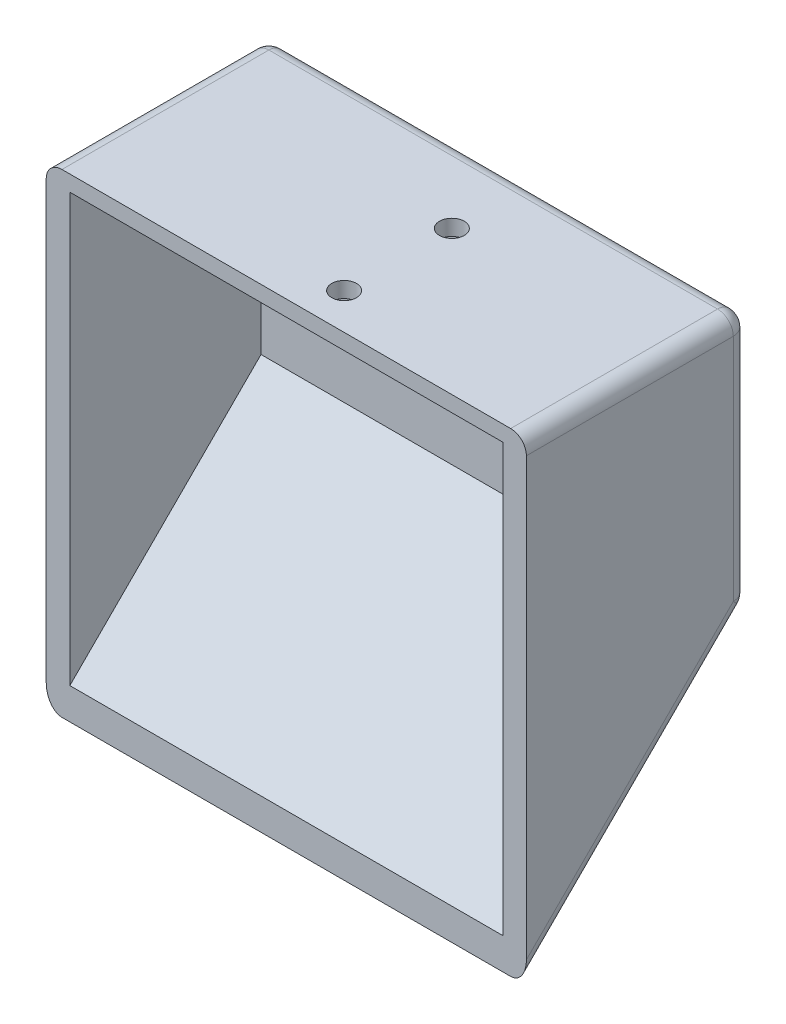
from build123d import *

# Parameters (mm, degrees)
SKETCH1_W           = 69.85
SKETCH1_H           = 38.1
BOSS_EXTRUDE1_DEPTH = 5.08
BOSS_EXTRUDE2_DEPTH = 69.85
BOSS_EXTRUDE3_DEPTH = 3.81
BOSS_EXTRUDE4_DEPTH = 3.81
SKETCH6_W           = 77.47
SKETCH6_H           = 35.921024484
BOSS_EXTRUDE5_DEPTH = 2.54
FILLET1_R           = 2.54
CUT_EXTRUDE1_DEPTH  = 2.54


with BuildPart() as part:
    # Sketch1 → Boss-Extrude1 (new body)
    with BuildSketch(Plane.XY):
        Rectangle(SKETCH1_W, SKETCH1_H)
    extrude(amount=BOSS_EXTRUDE1_DEPTH)

    # Sketch2 → Boss-Extrude2 (add)
    with BuildSketch(Plane.ZY.offset(34.925)):
        Polygon((5.08, -19.05), (20.200368371, -34.170368371), (29.556522172, -43.526522172), (35.921024484, -49.891024484), (35.921024484, -54.971024484), (0, -19.05), align=None)
    extrude(amount=-BOSS_EXTRUDE2_DEPTH)

    # Sketch3 → Boss-Extrude3 (add)
    with BuildSketch(Plane(origin=(34.925, 0, 0), x_dir=(0, 0, -1), z_dir=(1, 0, 0))):
        Polygon((-35.921024484, -54.971024484), (0, -19.05), (0, 19.05), (-35.921024484, 19.05), align=None)
    extrude(amount=BOSS_EXTRUDE3_DEPTH)

    # Sketch5 → Boss-Extrude4 (add)
    with BuildSketch(Plane.ZY.offset(34.925)):
        Polygon((5.08, 19.05), (35.921024484, 19.05), (35.921024484, -54.971024484), (0, -19.05), (0, 19.05), align=None)
    extrude(amount=BOSS_EXTRUDE4_DEPTH)

    # Sketch6 → Boss-Extrude5 (add)
    with BuildSketch(Plane(origin=(0, 19.05, 0), x_dir=(1, 0, 0), z_dir=(0, 1, 0))):
        with Locations((0, -17.960512242)):
            Rectangle(SKETCH6_W, SKETCH6_H)
    extrude(amount=BOSS_EXTRUDE5_DEPTH)

    # Fillet1
    fillet1_edges = [part.edges().sort_by_distance(p)[0] for p in [
        (38.735, -37.010512242, 17.960512242),
        (38.735, 1.27, 0),
        (-38.735, 1.27, 0),
        (-38.735, -37.010512242, 17.960512242),
        (0, -19.05, 0),
        (38.735, 21.59, 17.960512242),
        (0, 21.59, 0),
        (-38.735, 21.59, 17.960512242),
    ]]
    fillet(fillet1_edges, radius=FILLET1_R)

    # Sketch7 → Cut-Extrude1 (cut)
    with BuildSketch(Plane(origin=(0, 21.59, 0), x_dir=(1, 0, 0), z_dir=(0, 1, 0))):
        with BuildLine():
            ThreePointArc((5.483864, -12.7), (4.898077562, -11.285786438), (3.483864, -10.7))
            Line((3.483864, -10.7), (3.483864, -14.7))
            ThreePointArc((3.483864, -14.7), (4.898077562, -14.114213562), (5.483864, -12.7))
        make_face()
        with BuildLine():
            Line((3.483864, -14.7), (3.483864, -10.7))
            ThreePointArc((3.483864, -10.7), (1.483864, -12.7), (3.483864, -14.7))
        make_face()
        with BuildLine():
            ThreePointArc((5.483864, -30.079024484), (4.898077562, -28.664810922), (3.483864, -28.079024484))
            Line((3.483864, -28.079024484), (3.483864, -32.079024484))
            ThreePointArc((3.483864, -32.079024484), (4.898077562, -31.493238047), (5.483864, -30.079024484))
        make_face()
        with BuildLine():
            Line((3.483864, -32.079024484), (3.483864, -28.079024484))
            ThreePointArc((3.483864, -28.079024484), (1.483864, -30.079024484), (3.483864, -32.079024484))
        make_face()
    extrude(amount=-CUT_EXTRUDE1_DEPTH, mode=Mode.SUBTRACT)


solid = part.part
